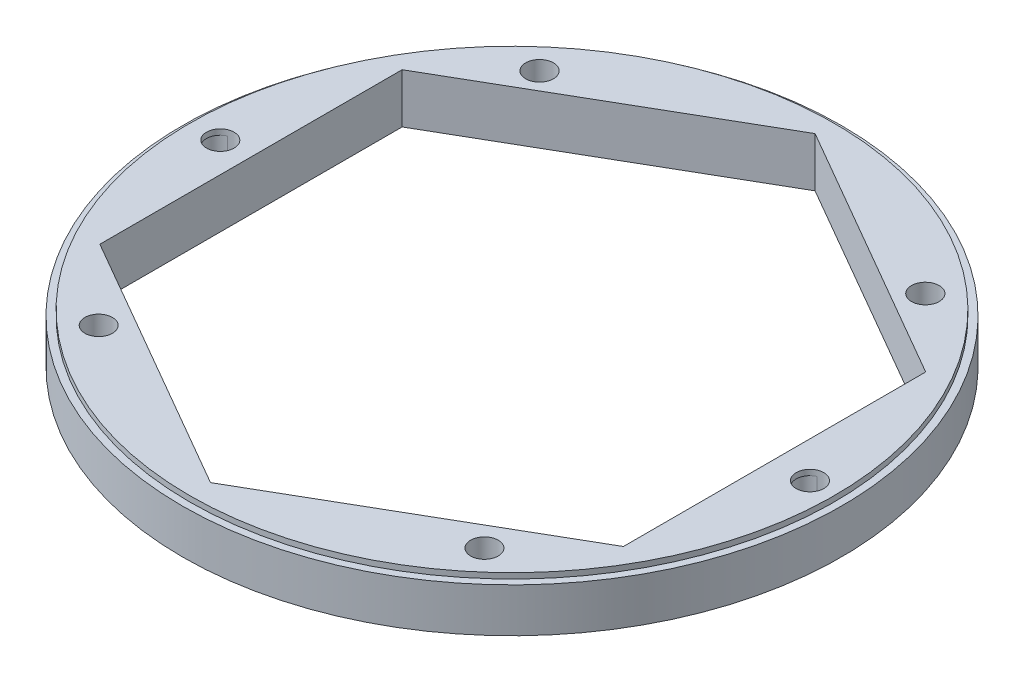
from build123d import *

# Parameters (mm, degrees)
SKETCH1_R               = 75.946
BOSS_EXTRUDE1_DEPTH     = 10.16
CUT_EXTRUDE4_DEPTH      = 11.16
SKETCH6_R               = 3.183478234
SKETCH6_R_2             = 3.2
SKETCH6_R_3             = 3.175
CUT_EXTRUDE5_DEPTH      = 1
CUT_EXTRUDE5_DEPTH_BACK = 11.16
SKETCH7_R               = 74.295
BOSS_EXTRUDE2_DEPTH     = 1.27
SKETCH8_R               = 3.183478234
SKETCH8_R_2             = 3.2
SKETCH8_R_3             = 3.175
CUT_EXTRUDE6_DEPTH      = 12.43
CUT_EXTRUDE7_DEPTH      = 12.43


with BuildPart() as part:
    # Sketch1 → Boss-Extrude1 (new body)
    with BuildSketch(Plane(origin=(0, 0, 0), x_dir=(1, 0, 0), z_dir=(0, 1, 0))):
        Circle(SKETCH1_R)
    extrude(amount=BOSS_EXTRUDE1_DEPTH)

    # Sketch5 → Cut-Extrude4 (cut, through all)
    with BuildSketch(Plane(origin=(0, 10.16, 0), x_dir=(1, 0, 0), z_dir=(0, 1, 0))):
        Polygon((0, 69.657309978), (-60.325, 34.828654989), (-60.325, -34.828654989), (0, -69.657309978), (60.325, -34.828654989), (60.325, 34.828654989), align=None)
    extrude(amount=-CUT_EXTRUDE4_DEPTH, mode=Mode.SUBTRACT)

    # Sketch6 → Cut-Extrude5 (cut, two sides)
    with BuildSketch(Plane(origin=(0, 10.16, 0), x_dir=(1, 0, 0), z_dir=(0, 1, 0))) as cut_extrude5_sk:
        with Locations((-67.945, 0)):
            Circle(SKETCH6_R)
        with Locations((-33.779572603, 58.808854795)):
            Circle(SKETCH6_R_2)
        with Locations((-33.953308147, -58.808854795)):
            Circle(SKETCH6_R_3)
        with Locations((33.953308147, -58.808854795)):
            Circle(SKETCH6_R_3)
        with Locations((67.945, 0)):
            Circle(SKETCH6_R)
        with Locations((33.779572603, 58.808854795)):
            Circle(SKETCH6_R_2)
    extrude(amount=CUT_EXTRUDE5_DEPTH, mode=Mode.SUBTRACT)
    extrude(cut_extrude5_sk.sketch, amount=-CUT_EXTRUDE5_DEPTH_BACK, mode=Mode.SUBTRACT)

    # Sketch7 → Boss-Extrude2 (add)
    with BuildSketch(Plane(origin=(0, 10.16, 0), x_dir=(1, 0, 0), z_dir=(0, 1, 0))):
        Circle(SKETCH7_R)
    extrude(amount=BOSS_EXTRUDE2_DEPTH)

    # Sketch8 → Cut-Extrude6 (cut, through all)
    with BuildSketch(Plane(origin=(0, 11.43, 0), x_dir=(1, 0, 0), z_dir=(0, 1, 0))):
        with Locations((-67.402457705, 0.180847432)):
            Circle(SKETCH8_R)
        with Locations((-44.45, 50.8)):
            Circle(SKETCH8_R_2)
        with Locations((-44.45, -50.8)):
            Circle(SKETCH8_R_3)
        with Locations((44.45, -50.8)):
            Circle(SKETCH8_R_3)
        with Locations((68.487542295, 0.180847432)):
            Circle(SKETCH8_R)
        with Locations((44.45, 50.8)):
            Circle(SKETCH8_R_2)
    extrude(amount=-CUT_EXTRUDE6_DEPTH, mode=Mode.SUBTRACT)

    # Sketch9 → Cut-Extrude7 (cut, through all)
    with BuildSketch(Plane(origin=(0, 11.43, 0), x_dir=(1, 0, 0), z_dir=(0, 1, 0))):
        Polygon((-0.180847432, 70.019004841), (-60.505847432, 35.190349852), (-60.505847432, -34.466960125), (-0.180847432, -69.295615114), (60.144152568, -34.466960125), (60.144152568, 35.190349852), align=None)
    extrude(amount=-CUT_EXTRUDE7_DEPTH, mode=Mode.SUBTRACT)


solid = part.part
